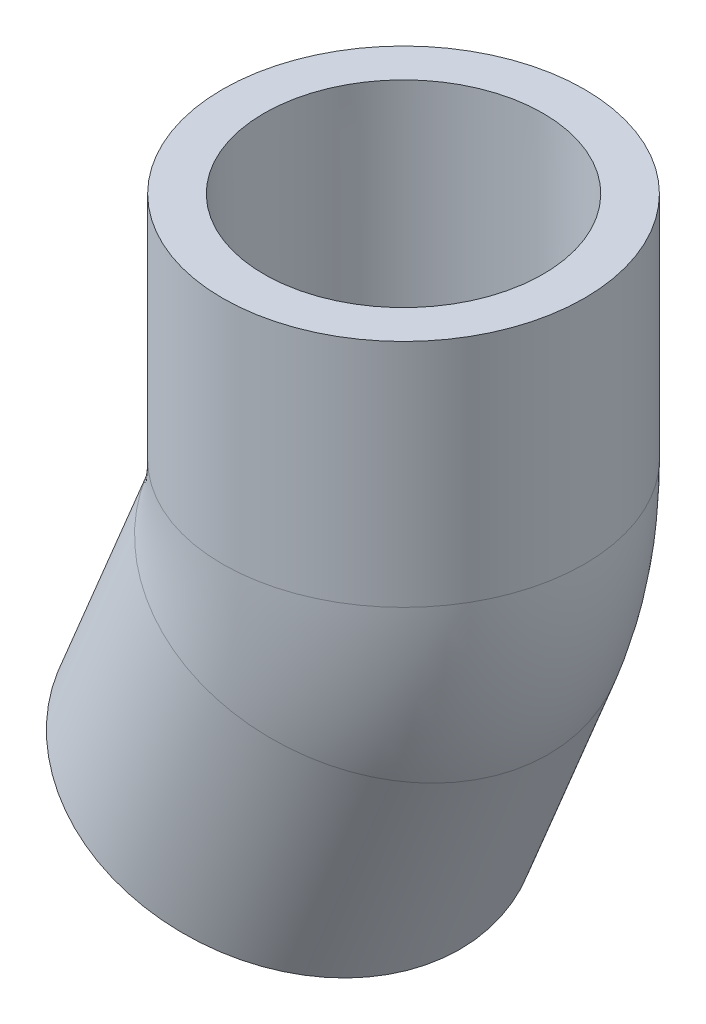
from build123d import *

# Parameters (mm, degrees)
SKETCH3_R   = 21.828125
SKETCH3_R_2 = 13.3223


with BuildPart() as part:
    # Sketch1 → Revolve1 (revolve)
    with BuildSketch(Plane.XY):
        Polygon((6.801339045, -40.61975447), (17.432763151, -14.953226207), (12.636789012, -12.966668675), (2.181363958, -38.706098131), align=None)
    revolve(axis=Axis((-13.365218875, -32.266492673, 0), (0.382683432, 0.923879533, 0)))



with BuildPart() as body_2:
    # Sketch2 → Revolve2 (revolve)
    with BuildSketch(Plane.XY):
        Polygon((16.8275, 34.925), (16.637, 7.14375), (21.828125, 7.14375), (21.828125, 34.925), align=None)
    revolve(axis=Axis((0, 0, 0), (0, 1, 0)))


with BuildPart() as part_1:
    add(part.part)

    add(body_2.part)  # Sweep1 merges body 2
    # Sweep1: sweep along a path in Sketch4
    with BuildLine(Plane.XY) as sweep1_path:
        ThreePointArc((-2.73379477, -6.59996441), (-0.690078525, 0.137265153), (0, 7.14375))
    # Sketch3 → Sweep1 (sweep)
    with BuildSketch(Plane(origin=(-2.73379477, -6.59996441, 0), x_dir=(0, 0, -1), z_dir=(0.382683432, 0.923879533, 0))):
        Circle(SKETCH3_R)
        Circle(SKETCH3_R_2, mode=Mode.SUBTRACT)
    sweep(path=sweep1_path.line)


solid = part_1.part
